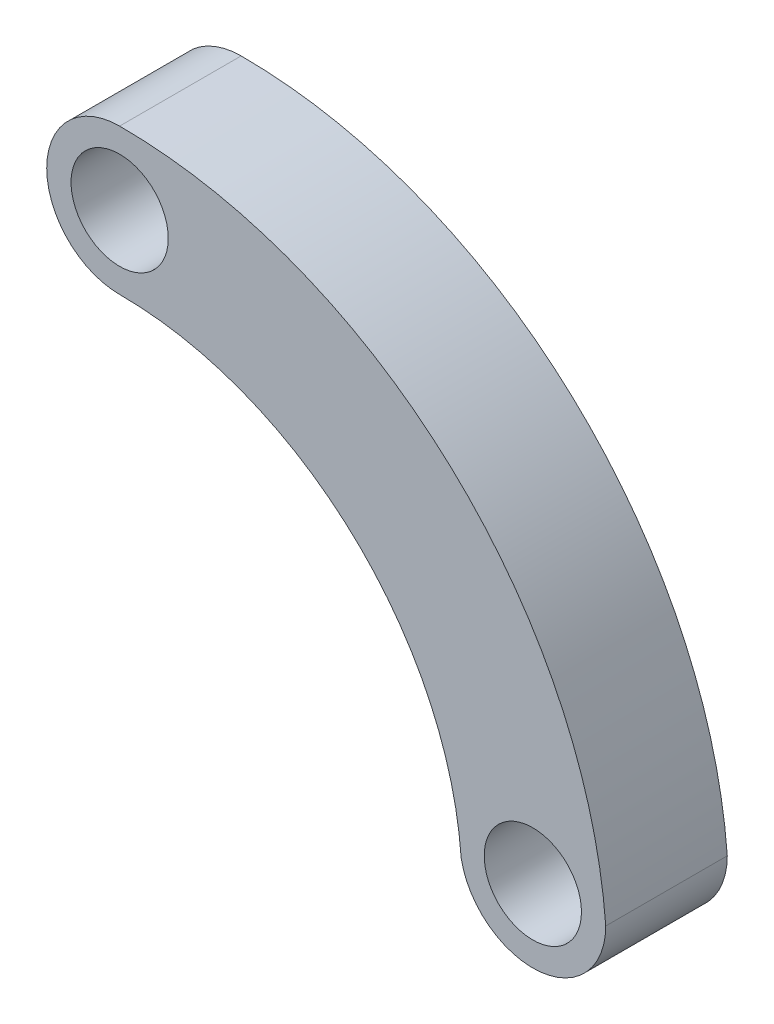
from build123d import *

# Parameters (mm, degrees)
CROQUIS1_R              = 20
SALIENTE_EXTRUIR1_DEPTH = 50


with BuildPart() as part:
    # Croquis1 → Saliente-Extruir1 (new body)
    with BuildSketch(Plane.XY):
        with BuildLine():
            ThreePointArc((140.520313479, -160.563100092), (95.907092551, -67.678686317), (0, -30))
            ThreePointArc((0, -30), (-30, 0), (0, 30))
            ThreePointArc((0, 30), (136.221327258, -23.341808369), (200, -155))
            ThreePointArc((200, -155), (172.793689709, -184.869638394), (140.520313479, -160.563100092))
        make_face()
        with Locations((170, -155)):
            Circle(CROQUIS1_R, mode=Mode.SUBTRACT)
        Circle(CROQUIS1_R, mode=Mode.SUBTRACT)
    extrude(amount=SALIENTE_EXTRUIR1_DEPTH)


solid = part.part
